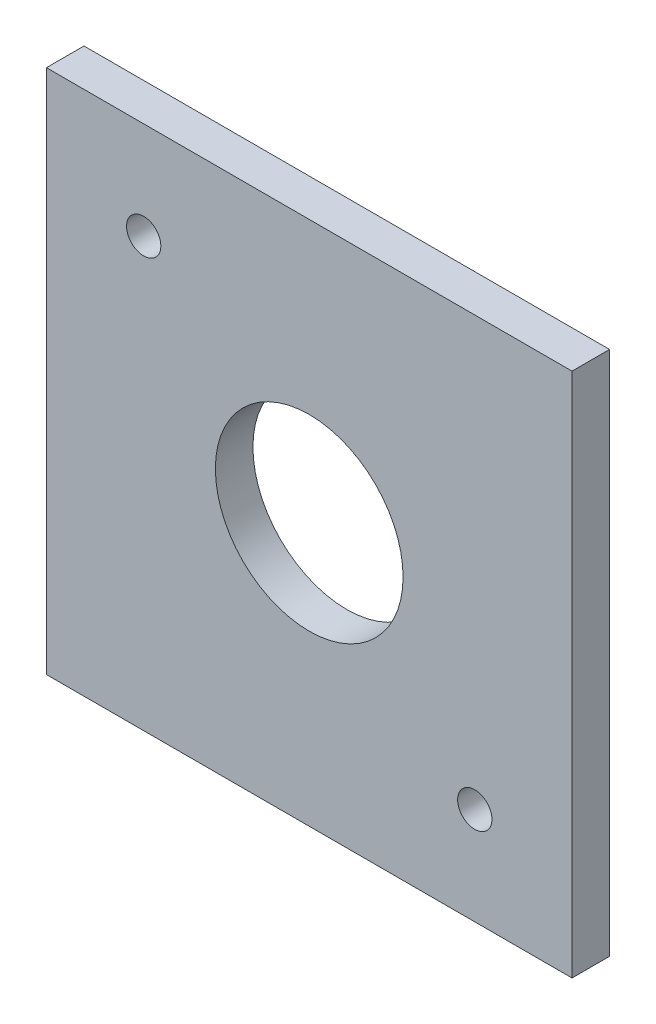
from build123d import *

# Parameters (mm, degrees)
SKETCH1_W              = 44.45
SKETCH1_H              = 44.45
BOSS_EXTRUDE1_DEPTH    = 3.175
M2_5_CLEARANCE_HOLE1_D = 2.9
SKETCH5_R              = 7.9375
CUT_EXTRUDE1_DEPTH     = 4.175


with BuildPart() as part:
    # Sketch1 → Boss-Extrude1 (new body)
    with BuildSketch(Plane.XY):
        Rectangle(SKETCH1_W, SKETCH1_H)
    extrude(amount=BOSS_EXTRUDE1_DEPTH)

    # M2.5 Clearance Hole1 (through all)
    with Locations(Plane.XY.offset(3.175)):
        with Locations((-14, 14), (14, -14)):
            Hole(M2_5_CLEARANCE_HOLE1_D / 2)

    # Sketch5 → Cut-Extrude1 (cut, through all)
    with BuildSketch(Plane.XY.offset(3.175)):
        Circle(SKETCH5_R)
    extrude(amount=-CUT_EXTRUDE1_DEPTH, mode=Mode.SUBTRACT)


solid = part.part
